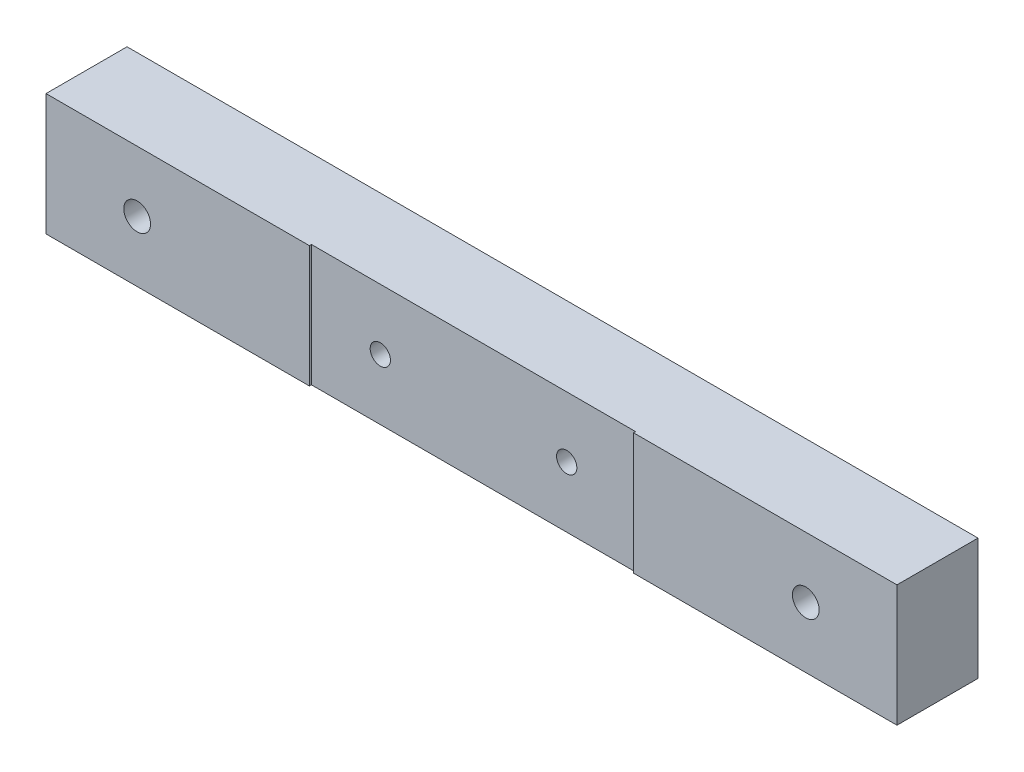
from build123d import *

# Parameters (mm, degrees)
SKETCH1_W                                      = 210
SKETCH1_H                                      = 30
EXTRUDE1_DEPTH                                 = 20
CBORE_FOR_M6_HEX_HEAD_FLANGE_BOLT1_D           = 6.6
CBORE_FOR_M6_HEX_HEAD_FLANGE_BOLT1_CBORE_D     = 16
CBORE_FOR_M6_HEX_HEAD_FLANGE_BOLT1_CBORE_DEPTH = 6.6
CUT_EXTRUDE1_REACH                             = 32
SKETCH4_W                                      = 80
SKETCH4_H                                      = 0.5
M6_TAPPED_HOLE1_D                              = 5


with BuildPart() as part:
    # Sketch1 → Extrude1 (new body)
    with BuildSketch(Plane.XY):
        Rectangle(SKETCH1_W, SKETCH1_H)
    extrude(amount=EXTRUDE1_DEPTH)

    # CBORE for M6 Hex Head Flange Bolt1 (through all)
    with Locations(Plane(origin=(0, 0, 0), x_dir=(-1, 0, 0), z_dir=(0, 0, -1))):
        with Locations((82.5, 0), (-82.5, 0)):
            CounterBoreHole(CBORE_FOR_M6_HEX_HEAD_FLANGE_BOLT1_D / 2, CBORE_FOR_M6_HEX_HEAD_FLANGE_BOLT1_CBORE_D / 2, CBORE_FOR_M6_HEX_HEAD_FLANGE_BOLT1_CBORE_DEPTH)

    # Sketch4 → Cut-Extrude1 (cut, up to next)
    with BuildSketch(Plane(origin=(0, 15, 0), x_dir=(1, 0, 0), z_dir=(0, 1, 0)), mode=Mode.PRIVATE) as cut_extrude1_sk1:
        with Locations((0, -19.75)):
            Rectangle(SKETCH4_W, SKETCH4_H)
    cut_extrude1_tool1 = extrude(cut_extrude1_sk1.sketch, amount=-CUT_EXTRUDE1_REACH, mode=Mode.PRIVATE) & part.part
    add(cut_extrude1_tool1.solids().sort_by_distance((0, 15, 19.75))[0], mode=Mode.SUBTRACT)

    # M6 Tapped Hole1 (through all)
    with Locations(Plane.XY.offset(19.5)):
        with Locations((-23, 0), (23, 0)):
            Hole(M6_TAPPED_HOLE1_D / 2)


solid = part.part
